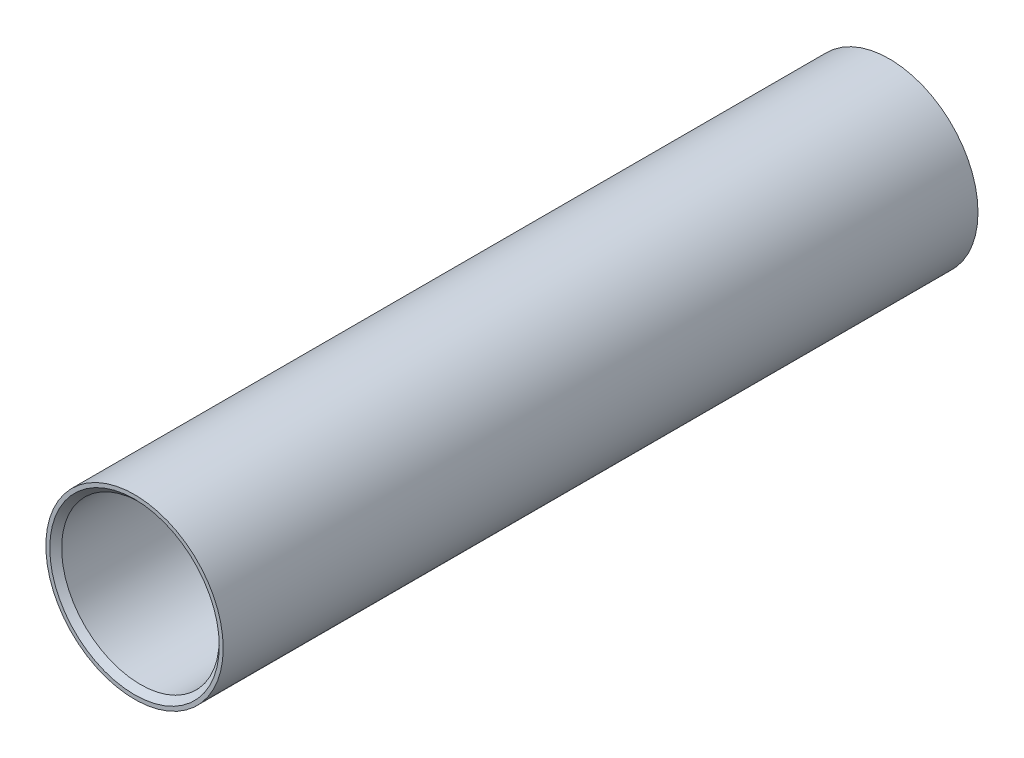
from build123d import *


with BuildPart() as part:
    # Sketch1 → Revolve1 (revolve)
    with BuildSketch(Plane(origin=(0, 0, 0), x_dir=(0, 0, -1), z_dir=(1, 0, 0))):
        Polygon((-19.15, 4.5), (19.15, 4.5), (19.15, 4.3), (18.85, 4), (-18.85, 4), (-19.15, 4.3), align=None)
    revolve(axis=Axis((0, 0, 0), (0, 0, -1)))


solid = part.part
